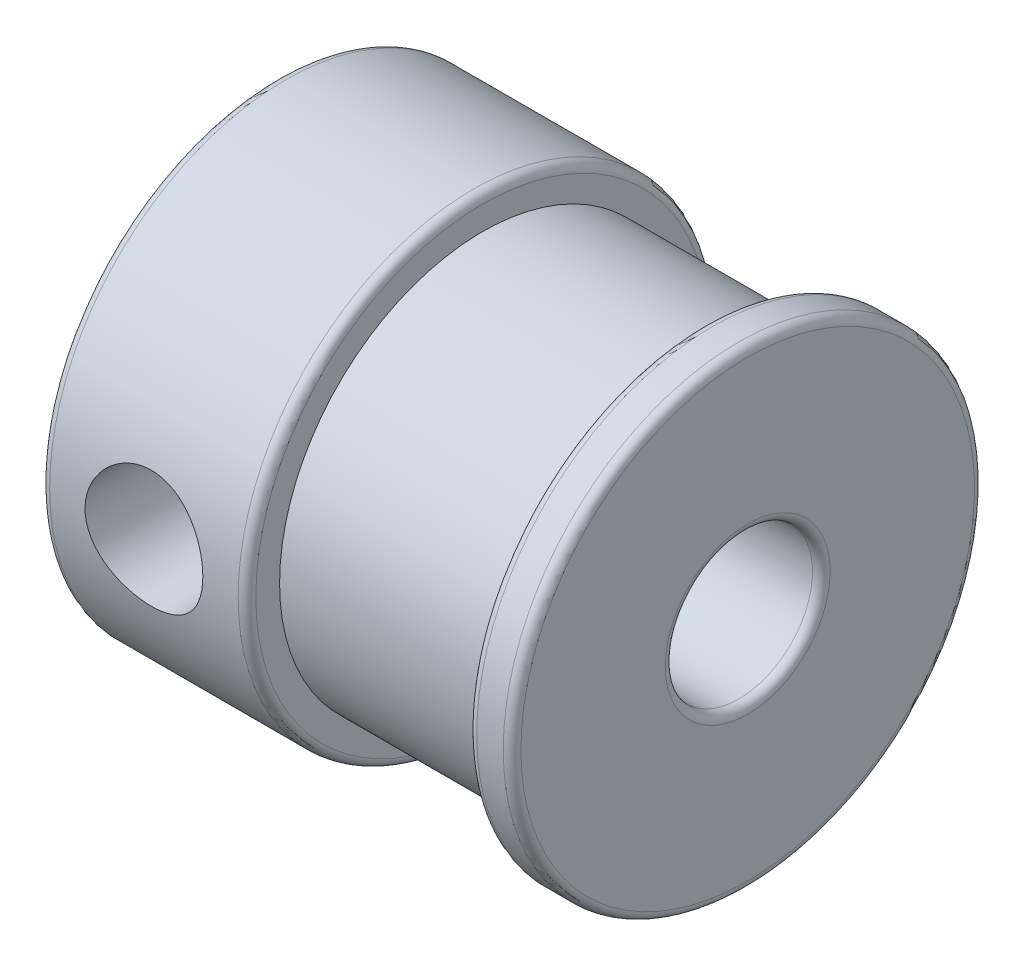
from build123d import *

# Parameters (mm, degrees)
FILLET1_R               = 0.3
SKETCH2_R               = 2
CUT_EXTRUDE1_DEPTH      = 9.0000001
CUT_EXTRUDE1_DEPTH_BACK = 9


with BuildPart() as part:
    # Sketch1 → Revolve1 (revolve)
    with BuildSketch(Plane(origin=(0, 0, 0), x_dir=(1, 0, 0), z_dir=(0, 1, 0))):
        Polygon((0, 2.5), (0, 8), (7, 8), (7, 6.89378315), (14.5, 6.89378315), (14.5, 8), (16, 8), (16, 2.5), align=None)
    revolve(axis=Axis((0, 0, 0), (1, 0, 0)))

    # Fillet1
    fillet1_edges = [part.edges().sort_by_distance(p)[0] for p in [
        (0, 0, 2.5),
        (16, 0, 2.5),
        (16, 0, 8),
        (14.5, 0, 8),
        (7, 0, 8),
        (0, 0, 8),
    ]]
    fillet(fillet1_edges, radius=FILLET1_R)

    # Sketch2 → Cut-Extrude1 (cut, two sides)
    with BuildSketch(Plane.XY) as cut_extrude1_sk:
        with Locations((3.5, 0)):
            Circle(SKETCH2_R)
    extrude(amount=CUT_EXTRUDE1_DEPTH, mode=Mode.SUBTRACT)
    extrude(cut_extrude1_sk.sketch, amount=-CUT_EXTRUDE1_DEPTH_BACK, mode=Mode.SUBTRACT)


solid = part.part
